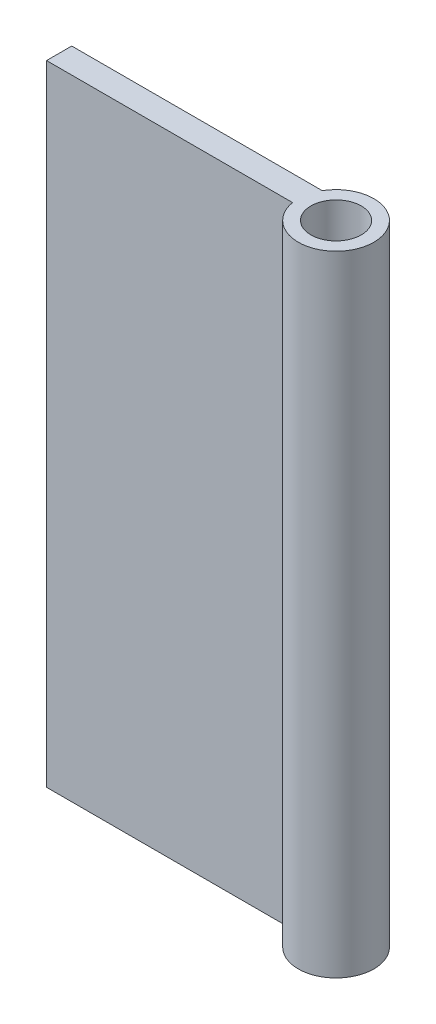
from build123d import *

# Parameters (mm, degrees)
SKETCH3_W           = 20
SKETCH3_H           = 50
BOSS_EXTRUDE2_DEPTH = 2
SKETCH4_R           = 3
SKETCH4_R_2         = 2
BOSS_EXTRUDE3_DEPTH = 50


with BuildPart() as part:
    # Sketch3 → Boss-Extrude2 (new body)
    with BuildSketch(Plane.XY):
        Rectangle(SKETCH3_W, SKETCH3_H)
    extrude(amount=BOSS_EXTRUDE2_DEPTH)

    # Sketch4 → Boss-Extrude3 (add)
    with BuildSketch(Plane(origin=(0, 25, 0), x_dir=(1, 0, 0), z_dir=(0, 1, 0))):
        with Locations((12.5, -1.5)):
            Circle(SKETCH4_R)
        with Locations((12.5, -1.5)):
            Circle(SKETCH4_R_2, mode=Mode.SUBTRACT)
    extrude(amount=-BOSS_EXTRUDE3_DEPTH)


solid = part.part
